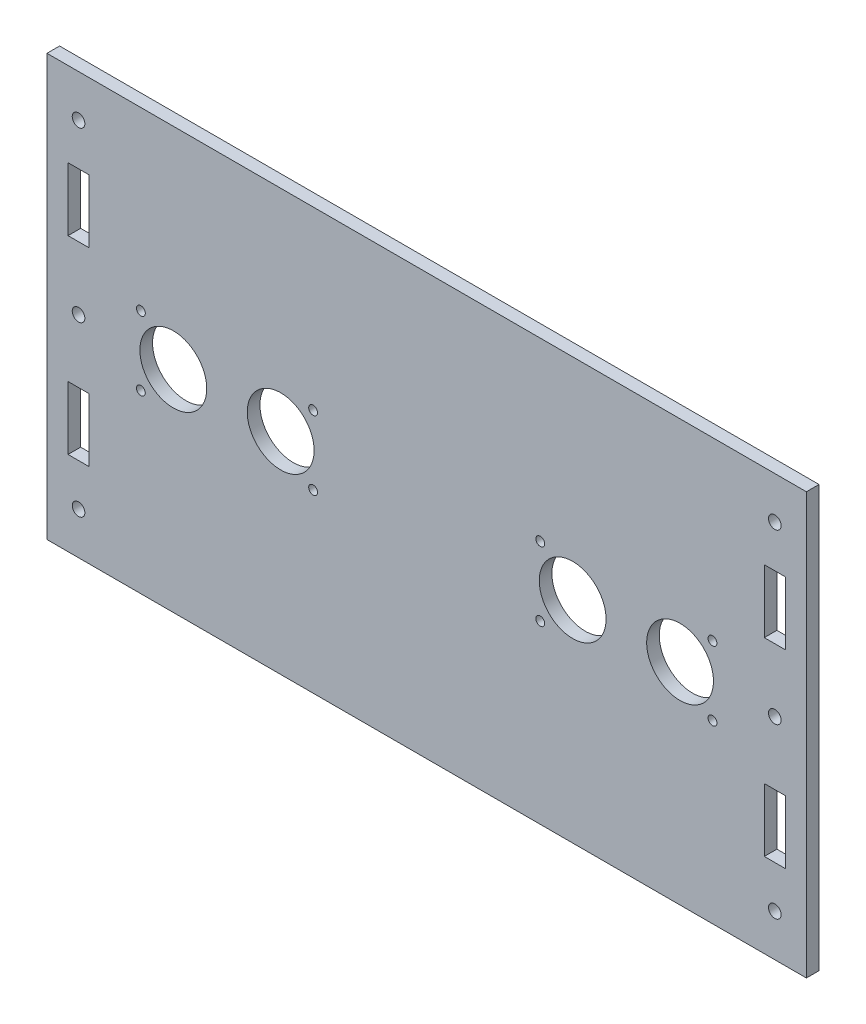
from build123d import *

# Parameters (mm, degrees)
SCHIZZO1_W                   = 180.34
SCHIZZO1_H                   = 100
ESTRUSIONE_ESTRUSIONE1_DEPTH = 3
SCHIZZO2_R                   = 1.5
SCHIZZO2_W                   = 5
SCHIZZO2_H                   = 15
TAGLIO_ESTRUSIONE1_DEPTH     = 4
SCHIZZO3_R                   = 7.94
SCHIZZO3_R_2                 = 1.05
TAGLIO_ESTRUSIONE2_DEPTH     = 4


with BuildPart() as part:
    # Schizzo1 → Estrusione-Estrusione1 (new body)
    with BuildSketch(Plane.XY):
        Rectangle(SCHIZZO1_W, SCHIZZO1_H)
    extrude(amount=ESTRUSIONE_ESTRUSIONE1_DEPTH)

    # Schizzo2 → Taglio-Estrusione1 (cut, through all)
    with BuildSketch(Plane.XY):
        with Locations((-82.67, 0)):
            Circle(SCHIZZO2_R)
        with Locations((82.67, 0)):
            Circle(SCHIZZO2_R)
        with Locations((-82.67, 40)):
            Circle(SCHIZZO2_R)
        with Locations((-82.67, -40)):
            Circle(SCHIZZO2_R)
        with Locations((82.67, -40)):
            Circle(SCHIZZO2_R)
        with Locations((82.67, 40)):
            Circle(SCHIZZO2_R)
        with Locations((-82.67, 22.5)):
            Rectangle(SCHIZZO2_W, SCHIZZO2_H)
        with Locations((-82.67, -22.5)):
            Rectangle(SCHIZZO2_W, SCHIZZO2_H)
        with Locations((82.67, 22.5)):
            Rectangle(SCHIZZO2_W, SCHIZZO2_H)
        with Locations((82.67, -22.5)):
            Rectangle(SCHIZZO2_W, SCHIZZO2_H)
    extrude(amount=TAGLIO_ESTRUSIONE1_DEPTH, mode=Mode.SUBTRACT)

    # Schizzo3 → Taglio-Estrusione2 (cut, through all)
    with BuildSketch(Plane.XY):
        with Locations((-60.17, 0)):
            Circle(SCHIZZO3_R)
        with Locations((-34.67, 0)):
            Circle(SCHIZZO3_R)
        with Locations((60.17, 0)):
            Circle(SCHIZZO3_R)
        with Locations((34.67, 0)):
            Circle(SCHIZZO3_R)
        with Locations((-26.97, -8.2)):
            Circle(SCHIZZO3_R_2)
        with Locations((-26.97, 8.2)):
            Circle(SCHIZZO3_R_2)
        with Locations((-67.87, -8.2)):
            Circle(SCHIZZO3_R_2)
        with Locations((-67.87, 8.2)):
            Circle(SCHIZZO3_R_2)
        with Locations((26.97, 8.2)):
            Circle(SCHIZZO3_R_2)
        with Locations((26.97, -8.2)):
            Circle(SCHIZZO3_R_2)
        with Locations((67.87, -8.2)):
            Circle(SCHIZZO3_R_2)
        with Locations((67.87, 8.2)):
            Circle(SCHIZZO3_R_2)
    extrude(amount=TAGLIO_ESTRUSIONE2_DEPTH, mode=Mode.SUBTRACT)


solid = part.part
